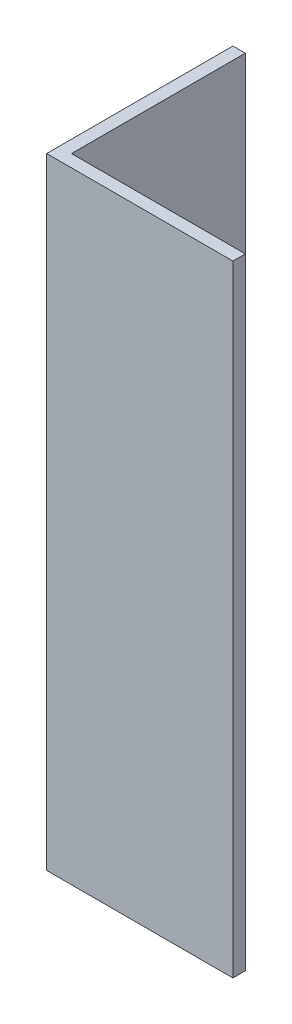
from build123d import *

# Parameters (mm, degrees)
EXTRUDE_1_DEPTH = 50


with BuildPart() as part:
    # Эскиз1 → Бобышка-Вытянуть1 (new body)
    with BuildSketch(Plane(origin=(0, 0, 0), x_dir=(1, 0, 0), z_dir=(0, 1, 0))):
        Polygon((0, 0), (0, 15), (1, 15), (1, 1), (15, 1), (15, 0), align=None)
    extrude(amount=EXTRUDE_1_DEPTH)


solid = part.part
